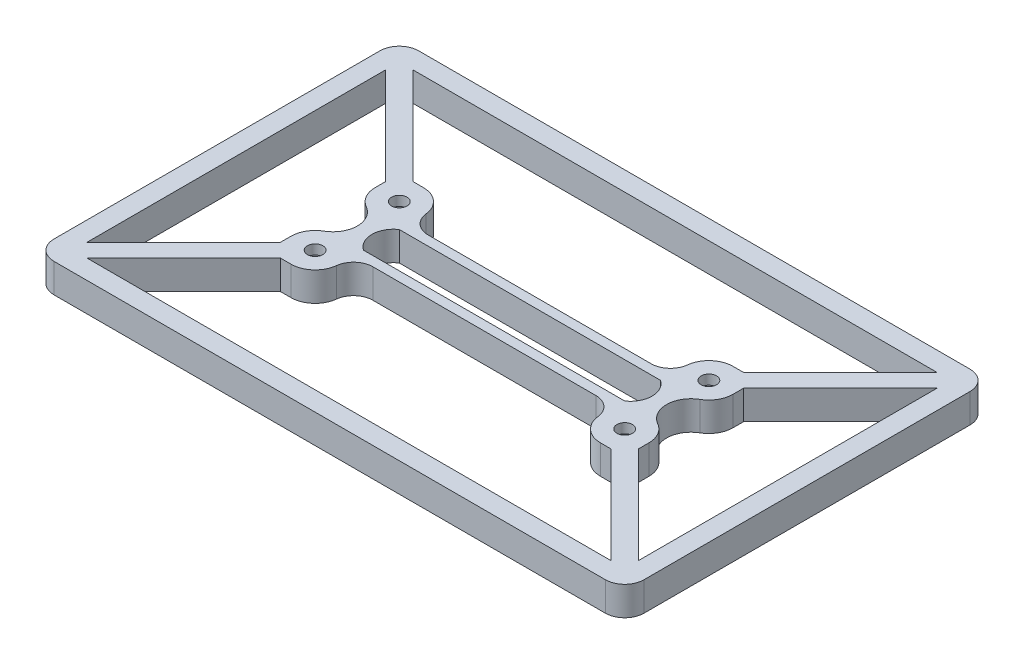
from build123d import *

# Parameters (mm, degrees)
CROQUIS1_R              = 1.6
SALIENTE_EXTRUIR1_DEPTH = 6
CROQUIS1_3_R            = 4
CROQUIS1_3_R_2          = 1.6
CORTAR_EXTRUIR1_DEPTH   = 4
REDONDEO1_R             = 4


with BuildPart() as part:
    # Croquis1 → Saliente-Extruir1 (new body)
    with BuildSketch(Plane(origin=(0, 0, 0), x_dir=(1, 0, 0), z_dir=(0, 1, 0))):
        with BuildLine():
            Line((57, 37.7), (-57, 37.7))
            ThreePointArc((-57, 37.7), (-59.828427125, 36.528427125), (-61, 33.7))
            Line((-61, 33.7), (-61, -33.7))
            ThreePointArc((-61, -33.7), (-59.828427125, -36.528427125), (-57, -37.7))
            Line((-57, -37.7), (57, -37.7))
            ThreePointArc((57, -37.7), (59.828427125, -36.528427125), (61, -33.7))
            Line((61, -33.7), (61, 33.7))
            ThreePointArc((61, 33.7), (59.828427125, 36.528427125), (57, 37.7))
        make_face()
        with BuildLine():
            Line((-57, 30.871572875), (-37, 10.871572875))
            Line((-37, 10.871572875), (-37, 8.7))
            ThreePointArc((-37, 8.7), (-36.327649298, 6.195713365), (-34.491419379, 4.36493028))
            ThreePointArc((-34.491419379, 4.36493028), (-31.965559308, 0), (-34.491419379, -4.36493028))
            ThreePointArc((-34.491419379, -4.36493028), (-36.327649298, -6.195713365), (-37, -8.7))
            Line((-37, -8.7), (-37, -10.871572875))
            Line((-37, -10.871572875), (-57, -30.871572875))
            Line((-57, -30.871572875), (-57, 30.871572875))
        make_face(mode=Mode.SUBTRACT)
        with BuildLine():
            Line((-34.171572875, 13.7), (-54.171572875, 33.7))
            Line((-54.171572875, 33.7), (54.171572875, 33.7))
            Line((54.171572875, 33.7), (34.171572875, 13.7))
            Line((34.171572875, 13.7), (32, 13.7))
            ThreePointArc((32, 13.7), (28.464466094, 12.235533906), (27, 8.7))
            Line((27, 8.7), (27, 5.7))
            Line((27, 5.7), (-27, 5.7))
            Line((-27, 5.7), (-27, 8.7))
            ThreePointArc((-27, 8.7), (-28.464466094, 12.235533906), (-32, 13.7))
            Line((-32, 13.7), (-34.171572875, 13.7))
        make_face(mode=Mode.SUBTRACT)
        with BuildLine():
            Line((-27, 3.7), (27, 3.7))
            ThreePointArc((27, 3.7), (28.961617728, 0), (27, -3.7))
            Line((27, -3.7), (-27, -3.7))
            ThreePointArc((-27, -3.7), (-28.961617728, 0), (-27, 3.7))
        make_face(mode=Mode.SUBTRACT)
        with BuildLine():
            Line((37, 8.7), (37, 10.871572875))
            Line((37, 10.871572875), (57, 30.871572875))
            Line((57, 30.871572875), (57, -30.871572875))
            Line((57, -30.871572875), (37, -10.871572875))
            Line((37, -10.871572875), (37, -8.7))
            ThreePointArc((37, -8.7), (36.327649298, -6.195713365), (34.491419379, -4.36493028))
            ThreePointArc((34.491419379, -4.36493028), (31.965559308, 0), (34.491419379, 4.36493028))
            ThreePointArc((34.491419379, 4.36493028), (36.327649298, 6.195713365), (37, 8.7))
        make_face(mode=Mode.SUBTRACT)
        with BuildLine():
            Line((32, -13.7), (34.171572875, -13.7))
            Line((34.171572875, -13.7), (54.171572875, -33.7))
            Line((54.171572875, -33.7), (-54.171572875, -33.7))
            Line((-54.171572875, -33.7), (-34.171572875, -13.7))
            Line((-34.171572875, -13.7), (-32, -13.7))
            ThreePointArc((-32, -13.7), (-28.464466094, -12.235533906), (-27, -8.7))
            Line((-27, -8.7), (-27, -5.7))
            Line((-27, -5.7), (27, -5.7))
            Line((27, -5.7), (27, -8.7))
            ThreePointArc((27, -8.7), (28.464466094, -12.235533906), (32, -13.7))
        make_face(mode=Mode.SUBTRACT)
        with Locations((32, 8.7)):
            Circle(CROQUIS1_R, mode=Mode.SUBTRACT)
        with Locations((-32, -8.7)):
            Circle(CROQUIS1_R, mode=Mode.SUBTRACT)
        with Locations((32, -8.7)):
            Circle(CROQUIS1_R, mode=Mode.SUBTRACT)
        with Locations((-32, 8.7)):
            Circle(CROQUIS1_R, mode=Mode.SUBTRACT)
    extrude(amount=SALIENTE_EXTRUIR1_DEPTH)

    # Croquis1_3 → Cortar-Extruir1 (cut)
    # profile 1 of 4: a face of its own
    with BuildSketch(Plane(origin=(0, 0, 0), x_dir=(1, 0, 0), z_dir=(0, 1, 0))):
        with Locations((-32, 8.7)):
            Circle(CROQUIS1_3_R)
        with Locations((-32, 8.7)):
            Circle(CROQUIS1_3_R_2, mode=Mode.SUBTRACT)
    # profile 2 of 4: a face of its own
    with BuildSketch(Plane(origin=(0, 0, 0), x_dir=(1, 0, 0), z_dir=(0, 1, 0))):
        with Locations((32, 8.7)):
            Circle(CROQUIS1_3_R)
        with Locations((32, 8.7)):
            Circle(CROQUIS1_3_R_2, mode=Mode.SUBTRACT)
    # profile 3 of 4: a face of its own
    with BuildSketch(Plane(origin=(0, 0, 0), x_dir=(1, 0, 0), z_dir=(0, 1, 0))):
        with Locations((32, -8.7)):
            Circle(CROQUIS1_3_R)
        with Locations((32, -8.7)):
            Circle(CROQUIS1_3_R_2, mode=Mode.SUBTRACT)
    # profile 4 of 4: a face of its own
    with BuildSketch(Plane(origin=(0, 0, 0), x_dir=(1, 0, 0), z_dir=(0, 1, 0))):
        with Locations((-32, -8.7)):
            Circle(CROQUIS1_3_R)
        with Locations((-32, -8.7)):
            Circle(CROQUIS1_3_R_2, mode=Mode.SUBTRACT)
    extrude(amount=CORTAR_EXTRUIR1_DEPTH, mode=Mode.SUBTRACT)

    # Redondeo1
    redondeo1_edges = [part.edges().sort_by_distance(p)[0] for p in [
        (27, 3, -5.7),
        (27, 3, 5.7),
        (-27, 3, -5.7),
        (-27, 3, 5.7),
    ]]
    fillet(redondeo1_edges, radius=REDONDEO1_R)


solid = part.part
